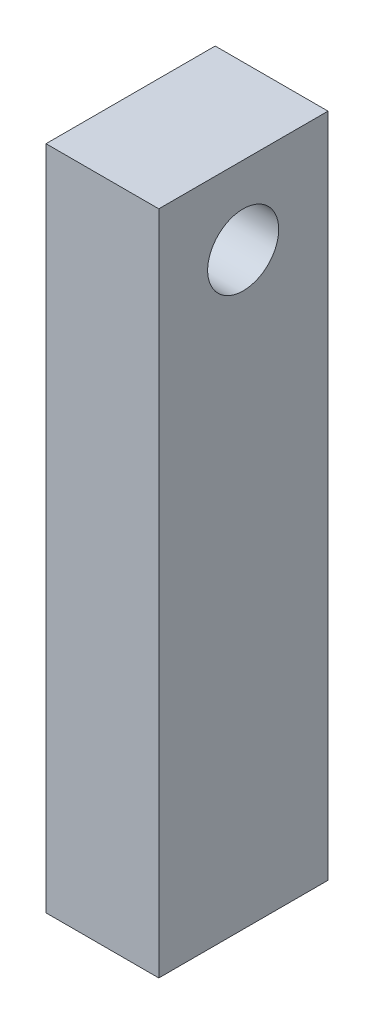
from build123d import *

# Parameters (mm, degrees)
SKETCH1_W           = 50.8
SKETCH1_H           = 76.2
BOSS_EXTRUDE1_DEPTH = 300
CUT_EXTRUDE1_DEPTH  = 150


with BuildPart() as part:
    # Sketch1 → Boss-Extrude1 (new body)
    with BuildSketch(Plane(origin=(0, 0, 0), x_dir=(1, 0, 0), z_dir=(0, 1, 0))):
        with Locations((25.4, 38.1)):
            Rectangle(SKETCH1_W, SKETCH1_H)
    extrude(amount=BOSS_EXTRUDE1_DEPTH)

    # Sketch2 → Cut-Extrude1 (cut)
    with BuildSketch(Plane(origin=(50.8, 0, 0), x_dir=(0, 0, -1), z_dir=(1, 0, 0))):
        with BuildLine():
            ThreePointArc((22, 265), (26.686291501, 253.686291501), (38, 249))
            Line((38, 249), (38, 265))
            Line((38, 265), (22, 265))
        make_face()
        with BuildLine():
            Line((38, 265), (38, 249))
            ThreePointArc((38, 249), (49.313708499, 253.686291501), (54, 265))
            ThreePointArc((54, 265), (38, 281), (22, 265))
            Line((22, 265), (38, 265))
        make_face()
    extrude(amount=-CUT_EXTRUDE1_DEPTH, mode=Mode.SUBTRACT)


solid = part.part
